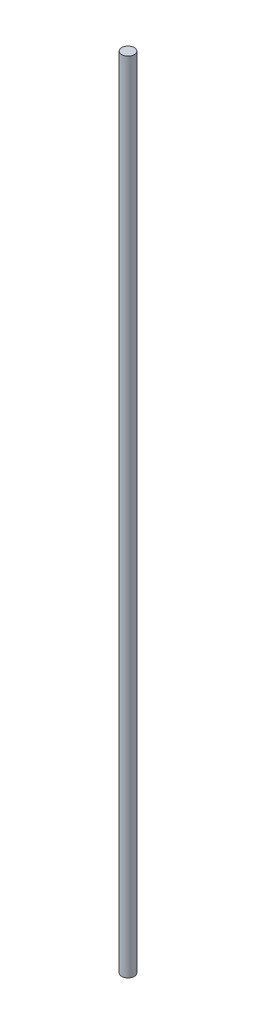
from build123d import *

# Parameters (mm, degrees)
SKETCH1_R           = 19.05
BOSS_EXTRUDE1_DEPTH = 2438.4


with BuildPart() as part:
    # Sketch1 → Boss-Extrude1 (new body)
    with BuildSketch(Plane(origin=(0, 0, 0), x_dir=(1, 0, 0), z_dir=(0, 1, 0))):
        Circle(SKETCH1_R)
    extrude(amount=BOSS_EXTRUDE1_DEPTH)


solid = part.part
